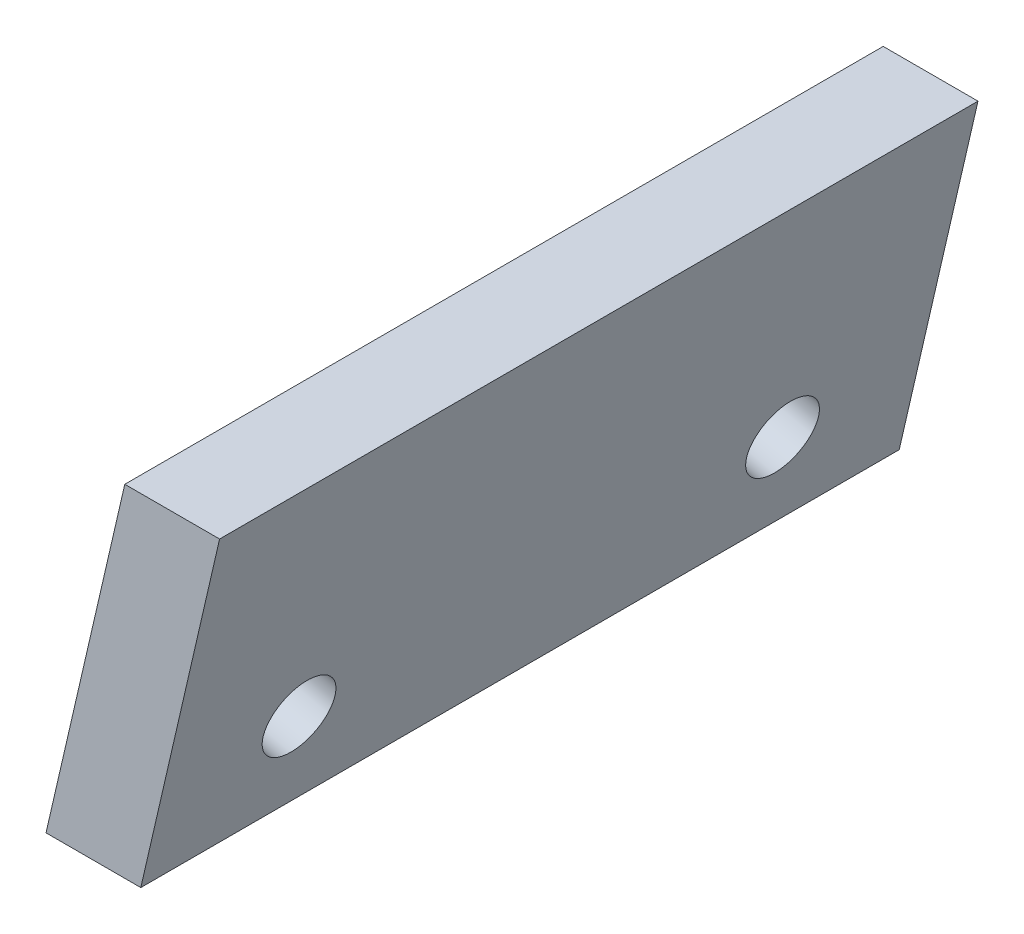
from build123d import *

# Parameters (mm, degrees)
BOSS_EXTRUDE2_DEPTH = 20
SKETCH4_R           = 0.95
CUT_EXTRUDE1_DEPTH  = 5.460484651


with BuildPart() as part:
    # Sketch2 → Boss-Extrude2 (new body)
    with BuildSketch(Plane.XY):
        Polygon((0, 0), (2.5, 0), (4.57781372, 9), (2.07781372, 9), align=None)
    extrude(amount=BOSS_EXTRUDE2_DEPTH)

    # Sketch4 → Cut-Extrude1 (cut, through all)
    with BuildSketch(Plane(origin=(0, 0, 0), x_dir=(0, 0, 1), z_dir=(-0.974370065, 0.224951054, 0))):
        with Locations((3.625, 3)):
            Circle(SKETCH4_R)
        with Locations((16.375, 3)):
            Circle(SKETCH4_R)
    extrude(amount=-CUT_EXTRUDE1_DEPTH, mode=Mode.SUBTRACT)


solid = part.part
